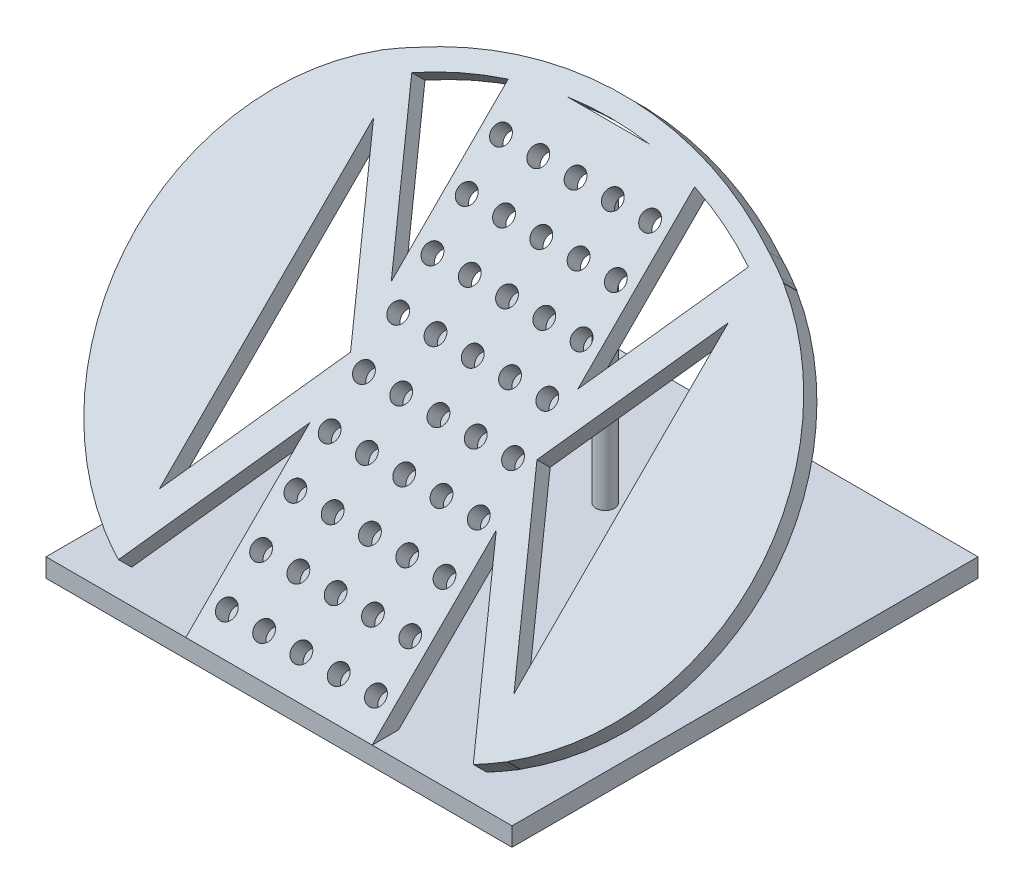
from build123d import *

# Parameters (mm, degrees)
SKETCH2_W            = 63.5
SKETCH2_H            = 63.5
BOSS_EXTRUDE1_DEPTH  = 2.54
BOSS_EXTRUDE2_DEPTH  = 2.54
SKETCH4_R            = 1.27
CUT_EXTRUDE1_DEPTH   = 2.54
BOSS_EXTRUDE3_DEPTH  = 2.54
BOSS_EXTRUDE4_DEPTH  = 2.54
EXTRUDE_THIN1_DEPTH  = 2.54
BOSS_EXTRUDE10_DEPTH = 2.54
SKETCH8_R            = 1.27
BOSS_EXTRUDE11_DEPTH = 42.418


with BuildPart() as part:
    # Sketch2 → Boss-Extrude1 (new body)
    with BuildSketch(Plane(origin=(0, 0, 0), x_dir=(1, 0, 0), z_dir=(0, 1, 0))):
        Rectangle(SKETCH2_W, SKETCH2_H)
    extrude(amount=BOSS_EXTRUDE1_DEPTH)

    # Sketch3 → Boss-Extrude2 (add)
    with BuildSketch(Plane(origin=(0, 17.145, 17.145), x_dir=(1, 0, 0), z_dir=(0, 0.7071067811865464, 0.7071067811865488))):
        Polygon((0, -20.654589078), (-12.7, -20.654589078), (-12.7, 42.845410922), (12.7, 42.845410922), (12.7, -20.654589078), align=None)
    extrude(amount=-BOSS_EXTRUDE2_DEPTH)

    # Sketch4 → Cut-Extrude1 (cut)
    with BuildSketch(Plane(origin=(0, 17.145, 17.145), x_dir=(1, 0, 0), z_dir=(0, 0.7071067811865465, 0.7071067811865487))):
        with Locations((0, 36.495410922)):
            Circle(SKETCH4_R)
        with Locations((-5.08, 36.495410922)):
            Circle(SKETCH4_R)
        with Locations((-10.16, 36.495410922)):
            Circle(SKETCH4_R)
        with Locations((5.08, 36.495410922)):
            Circle(SKETCH4_R)
        with Locations((10.16, 36.495410922)):
            Circle(SKETCH4_R)
        with Locations((-5.08, 29.891410922)):
            Circle(SKETCH4_R)
        with Locations((-10.16, 29.891410922)):
            Circle(SKETCH4_R)
        with Locations((0, 29.891410922)):
            Circle(SKETCH4_R)
        with Locations((5.08, 29.891410922)):
            Circle(SKETCH4_R)
        with Locations((-5.08, 23.287410922)):
            Circle(SKETCH4_R)
        with Locations((-10.16, 23.287410922)):
            Circle(SKETCH4_R)
        with Locations((0, 23.287410922)):
            Circle(SKETCH4_R)
        with Locations((5.08, 23.287410922)):
            Circle(SKETCH4_R)
        with Locations((-5.08, 16.683410922)):
            Circle(SKETCH4_R)
        with Locations((-10.16, 16.683410922)):
            Circle(SKETCH4_R)
        with Locations((0, 16.683410922)):
            Circle(SKETCH4_R)
        with Locations((5.08, 16.683410922)):
            Circle(SKETCH4_R)
        with Locations((-5.08, 10.079410922)):
            Circle(SKETCH4_R)
        with Locations((-10.16, 10.079410922)):
            Circle(SKETCH4_R)
        with Locations((0, 10.079410922)):
            Circle(SKETCH4_R)
        with Locations((5.08, 10.079410922)):
            Circle(SKETCH4_R)
        with Locations((-5.08, 3.475410922)):
            Circle(SKETCH4_R)
        with Locations((-10.16, 3.475410922)):
            Circle(SKETCH4_R)
        with Locations((0, 3.475410922)):
            Circle(SKETCH4_R)
        with Locations((5.08, 3.475410922)):
            Circle(SKETCH4_R)
        with Locations((-5.08, -3.128589078)):
            Circle(SKETCH4_R)
        with Locations((-10.16, -3.128589078)):
            Circle(SKETCH4_R)
        with Locations((0, -3.128589078)):
            Circle(SKETCH4_R)
        with Locations((5.08, -3.128589078)):
            Circle(SKETCH4_R)
        with Locations((-5.08, -9.732589078)):
            Circle(SKETCH4_R)
        with Locations((-10.16, -9.732589078)):
            Circle(SKETCH4_R)
        with Locations((0, -9.732589078)):
            Circle(SKETCH4_R)
        with Locations((5.08, -9.732589078)):
            Circle(SKETCH4_R)
        with Locations((-5.08, -16.336589078)):
            Circle(SKETCH4_R)
        with Locations((-10.16, -16.336589078)):
            Circle(SKETCH4_R)
        with Locations((0, -16.336589078)):
            Circle(SKETCH4_R)
        with Locations((5.08, -16.336589078)):
            Circle(SKETCH4_R)
        with Locations((10.16, 29.891410922)):
            Circle(SKETCH4_R)
        with Locations((10.16, 23.287410922)):
            Circle(SKETCH4_R)
        with Locations((10.16, 16.683410922)):
            Circle(SKETCH4_R)
        with Locations((10.16, 10.079410922)):
            Circle(SKETCH4_R)
        with Locations((10.16, 3.475410922)):
            Circle(SKETCH4_R)
        with Locations((10.16, -3.128589078)):
            Circle(SKETCH4_R)
        with Locations((10.16, -9.732589078)):
            Circle(SKETCH4_R)
        with Locations((10.16, -16.336589078)):
            Circle(SKETCH4_R)
    extrude(amount=-CUT_EXTRUDE1_DEPTH, mode=Mode.SUBTRACT)

    # Sketch5 → Boss-Extrude3 (add)
    with BuildSketch(Plane(origin=(0, 17.145, 17.145), x_dir=(1, 0, 0), z_dir=(0, 0.7071067811865465, 0.7071067811865487))):
        Polygon((12.7, 18.940681089), (12.7, 11.095410922), (27.502396542, 37.739724698), (24.17185732, 39.590024266), align=None)
        Polygon((27.500255446, -15.55009224), (12.7, 11.095410922), (12.7, 3.250490946), (24.17019797, -17.399774004), align=None)
    extrude(amount=-BOSS_EXTRUDE3_DEPTH)

    # Sketch6 → Boss-Extrude4 (add)
    with BuildSketch(Plane(origin=(0, 17.145, 17.145), x_dir=(1, 0, 0), z_dir=(0, 0.7071067811865465, 0.7071067811865487))):
        Polygon((-27.500255446, 37.740914083), (-12.7, 11.095410922), (-12.69936958, 18.940681064), (-24.169567551, 39.590946014), align=None)
        Polygon((-12.7, 3.250140754), (-12.7, 11.095410922), (-27.502396542, -15.548902855), (-24.17185732, -17.399202422), align=None)
    extrude(amount=-BOSS_EXTRUDE4_DEPTH)

    # Sketch7 → Extrude-Thin1 (add)
    with BuildSketch(Plane(origin=(0, 17.145, 17.145), x_dir=(1, 0, 0), z_dir=(0, 0.7071067811865465, 0.7071067811865487))):
        with BuildLine():
            ThreePointArc((-24.169567551, 39.590946014), (0.001261553, 45.709206507), (24.17185732, 39.590024266))
            Line((24.17185732, 39.590024266), (22.963279101, 37.355983378))
            ThreePointArc((22.963279101, 37.355983378), (0.001213122, 43.169206508), (-22.961074527, 37.356859039))
            Line((-22.961074527, 37.356859039), (-24.169567551, 39.590946014))
        make_face()
    extrude(amount=-EXTRUDE_THIN1_DEPTH)

    # Sketch7_6 → Boss-Extrude10 (add)
    with BuildSketch(Plane(origin=(0, 17.145, 17.145), x_dir=(1, 0, 0), z_dir=(0, 0.7071067811865465, 0.7071067811865487))):
        with BuildLine():
            ThreePointArc((-24.169567551, 39.590946014), (-41.917382675, 11.096584828), (-24.17185732, -17.399202422))
            Line((-24.17185732, -17.399202422), (-24.169567551, 39.590946014))
        make_face()
        with BuildLine():
            ThreePointArc((24.17185732, -17.398852317), (41.917233568, 11.095585974), (24.17185732, 39.590024266))
            Line((24.17185732, 39.590024266), (24.17185732, -17.398852317))
        make_face()
    extrude(amount=-BOSS_EXTRUDE10_DEPTH)

    # Sketch8 → Boss-Extrude11 (add)
    with BuildSketch(Plane(origin=(0, 2.54, 0), x_dir=(1, 0, 0), z_dir=(0, 1, 0))):
        with Locations((0, 12.7)):
            Circle(SKETCH8_R)
    extrude(amount=BOSS_EXTRUDE11_DEPTH)


solid = part.part
